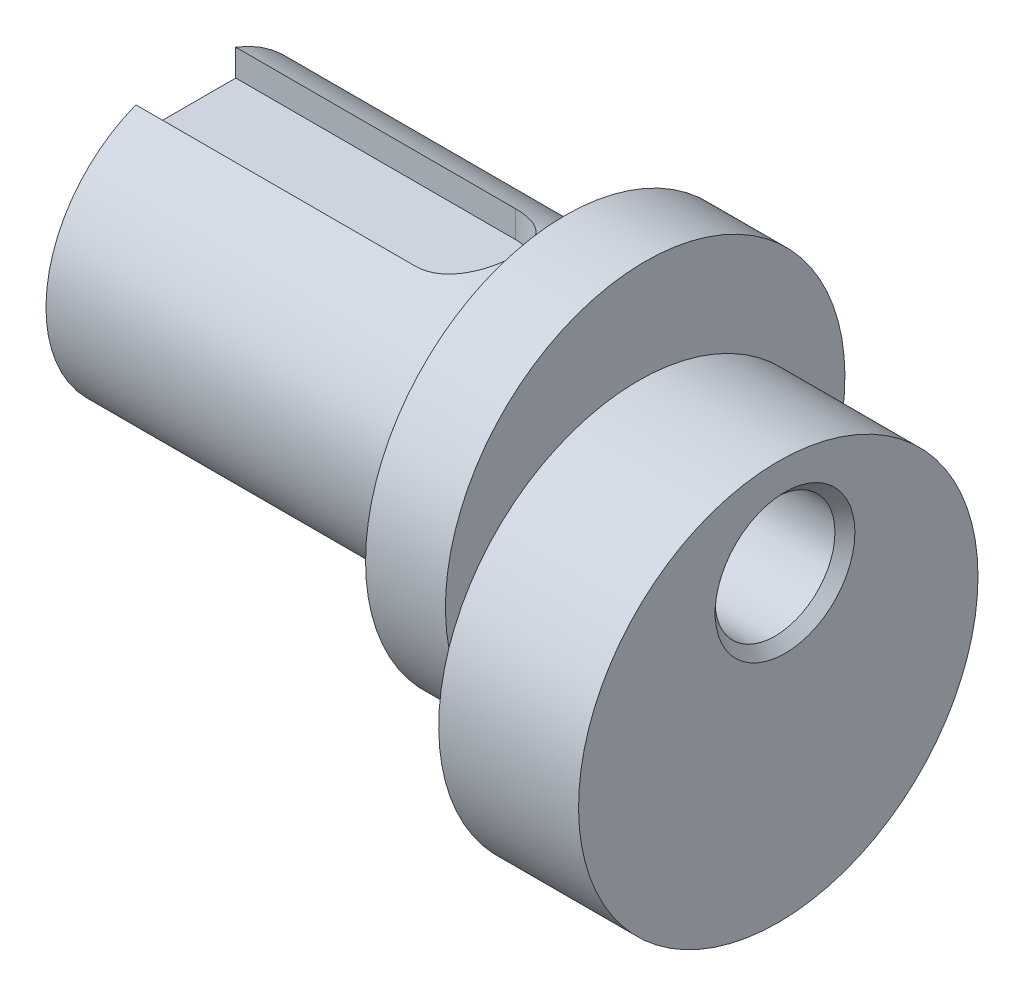
from build123d import *

# Parameters (mm, degrees)
SKETCH1_R           = 10
BOSS_EXTRUDE1_DEPTH = 7
SKETCH2_R           = 10
BOSS_EXTRUDE2_DEPTH = 4
SKETCH3_R           = 7
BOSS_EXTRUDE3_DEPTH = 19
SKETCH4_R           = 3
CUT_EXTRUDE1_DEPTH  = 31
CHAMFER1_SIZE       = 0.5
CUT_EXTRUDE2_START  = 10.2
CUT_EXTRUDE2_DEPTH  = 5.8


with BuildPart() as part:
    # Sketch1 → Boss-Extrude1 (new body)
    with BuildSketch(Plane(origin=(0, 0, 0), x_dir=(0, 0, -1), z_dir=(1, 0, 0))):
        Circle(SKETCH1_R)
    extrude(amount=BOSS_EXTRUDE1_DEPTH)

    # Sketch2 → Boss-Extrude2 (add)
    with BuildSketch(Plane.ZY):
        with Locations((-0.336496213, 5)):
            Circle(SKETCH2_R)
    extrude(amount=BOSS_EXTRUDE2_DEPTH)

    # Sketch3 → Boss-Extrude3 (add)
    with BuildSketch(Plane.ZY.offset(4)):
        with Locations((-0.336496213, 5)):
            Circle(SKETCH3_R)
    extrude(amount=BOSS_EXTRUDE3_DEPTH)

    # Sketch4 → Cut-Extrude1 (cut, through all)
    with BuildSketch(Plane.ZY.offset(23)):
        with Locations((-0.336496213, 5)):
            Circle(SKETCH4_R)
    extrude(amount=-CUT_EXTRUDE1_DEPTH, mode=Mode.SUBTRACT)

    # Chamfer1
    chamfer1_edges = [part.edges().sort_by_distance(p)[0] for p in [
        (7, 5, -3.336496213),
        (-23, 5, -3.336496213),
    ]]
    chamfer(chamfer1_edges, length=CHAMFER1_SIZE)

    # Sketch5 → Cut-Extrude2 (cut, through all)
    with BuildSketch(Plane(origin=(0, 0, 0), x_dir=(1, 0, 0), z_dir=(0, 1, 0)).offset(CUT_EXTRUDE2_START)):
        with BuildLine():
            Line((-9, 2.836496213), (-26.986787276, 2.836496213))
            Line((-26.986787276, 2.836496213), (-26.986787276, -2.163503787))
            Line((-26.986787276, -2.163503787), (-9, -2.163503787))
            ThreePointArc((-9, -2.163503787), (-6.5, 0.336496213), (-9, 2.836496213))
        make_face()
    extrude(amount=CUT_EXTRUDE2_DEPTH, mode=Mode.SUBTRACT)


solid = part.part
